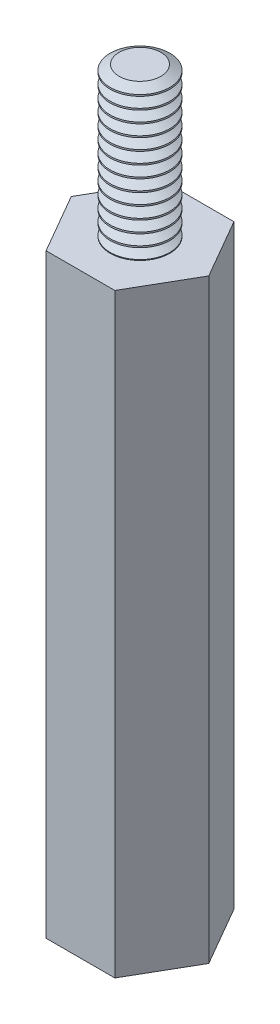
from build123d import *

# Parameters (mm, degrees)
BOSS_EXTRUDE1_DEPTH = 20
SKETCH3_R           = 0.8
CUT_EXTRUDE1_DEPTH  = 6
SKETCH2_R           = 1
BOSS_EXTRUDE2_DEPTH = 5
LPATTERN1_COUNT     = 15
LPATTERN1_PITCH     = 0.4
LPATTERN2_COUNT     = 13
LPATTERN2_PITCH     = 0.4


with BuildPart() as part:
    # Sketch1 → Boss-Extrude1 (new body)
    with BuildSketch(Plane(origin=(0, 0, 0), x_dir=(1, 0, 0), z_dir=(0, 1, 0))):
        Polygon((2.309401077, 0), (1.154700538, 2), (-1.154700538, 2), (-2.309401077, 0), (-1.154700538, -2), (1.154700538, -2), align=None)
    extrude(amount=BOSS_EXTRUDE1_DEPTH)

    # Sketch3 → Cut-Extrude1 (cut)
    with BuildSketch(Plane.XZ):
        Circle(SKETCH3_R)
    extrude(amount=-CUT_EXTRUDE1_DEPTH, mode=Mode.SUBTRACT)

    # Sketch2 → Boss-Extrude2 (add)
    with BuildSketch(Plane(origin=(0, 20, 0), x_dir=(1, 0, 0), z_dir=(0, 1, 0))):
        Circle(SKETCH2_R)
    extrude(amount=BOSS_EXTRUDE2_DEPTH)

    # Sketch5 → Cut-Revolve1 (revolve, cut)
    with BuildSketch(Plane.XY):
        Polygon((0.38, 0.2), (0.38, -0.2), (0.78, -0.2), (1.126410162, 0), (0.78, 0.2), align=None)
    cut_revolve1 = revolve(axis=Axis((0, 0, 0), (0, 1, 0)), mode=Mode.SUBTRACT)

    # LPattern1: Cut-Revolve1 ×15
    with Locations(*[(0, i * LPATTERN1_PITCH, 0) for i in range(1, LPATTERN1_COUNT)]):
        add(cut_revolve1, mode=Mode.SUBTRACT)

    # Sketch6 → Cut-Revolve2 (revolve, cut)
    with BuildSketch(Plane.XY):
        Polygon((1.446410162, 25.2), (1.446410162, 24.8), (1.046410162, 24.8), (0.7, 25), (1.046410162, 25.2), align=None)
    cut_revolve2 = revolve(axis=Axis((0, 0, 0), (0, 1, 0)), mode=Mode.SUBTRACT)

    # LPattern2: Cut-Revolve2 ×13
    with Locations(*[(0, -i * LPATTERN2_PITCH, 0) for i in range(1, LPATTERN2_COUNT)]):
        add(cut_revolve2, mode=Mode.SUBTRACT)


solid = part.part
